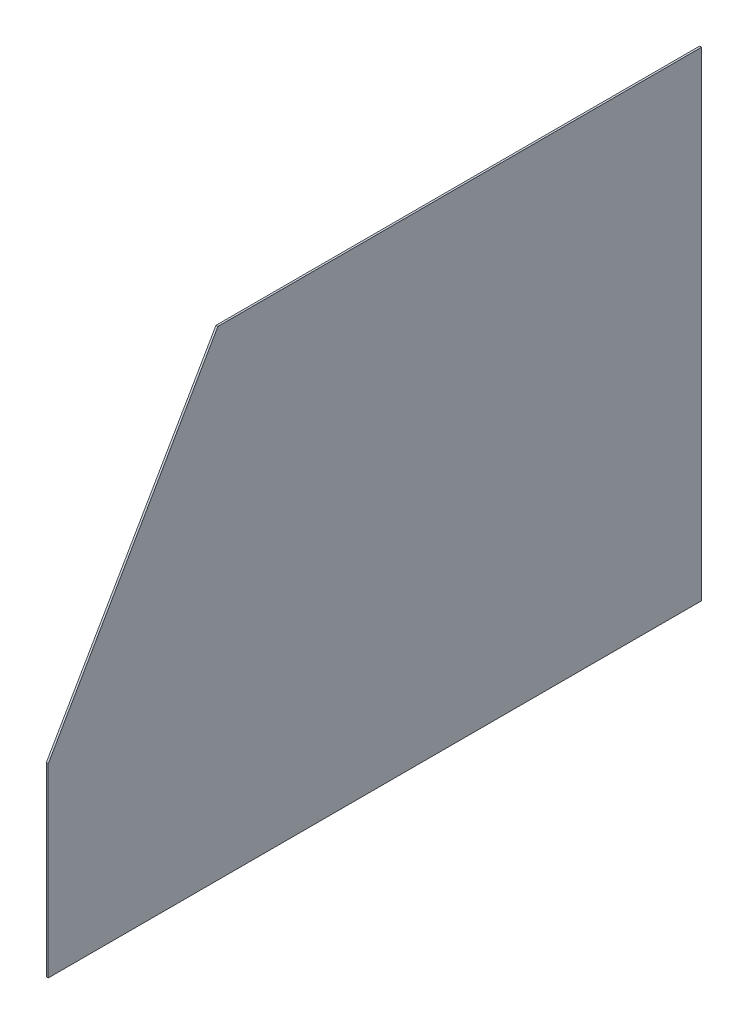
from build123d import *

# Parameters (mm, degrees)
BOSS_EXTRUDE1_DEPTH = 3.175


with BuildPart() as part:
    # Sketch1 → Boss-Extrude1 (new body)
    with BuildSketch(Plane(origin=(0, 0, 0), x_dir=(0, 0, -1), z_dir=(1, 0, 0))):
        Polygon((0, 0), (-794.520760089, 0), (-1073.15, -482.6), (-1073.15, -787.4), (0, -787.4), align=None)
    extrude(amount=BOSS_EXTRUDE1_DEPTH)


solid = part.part
